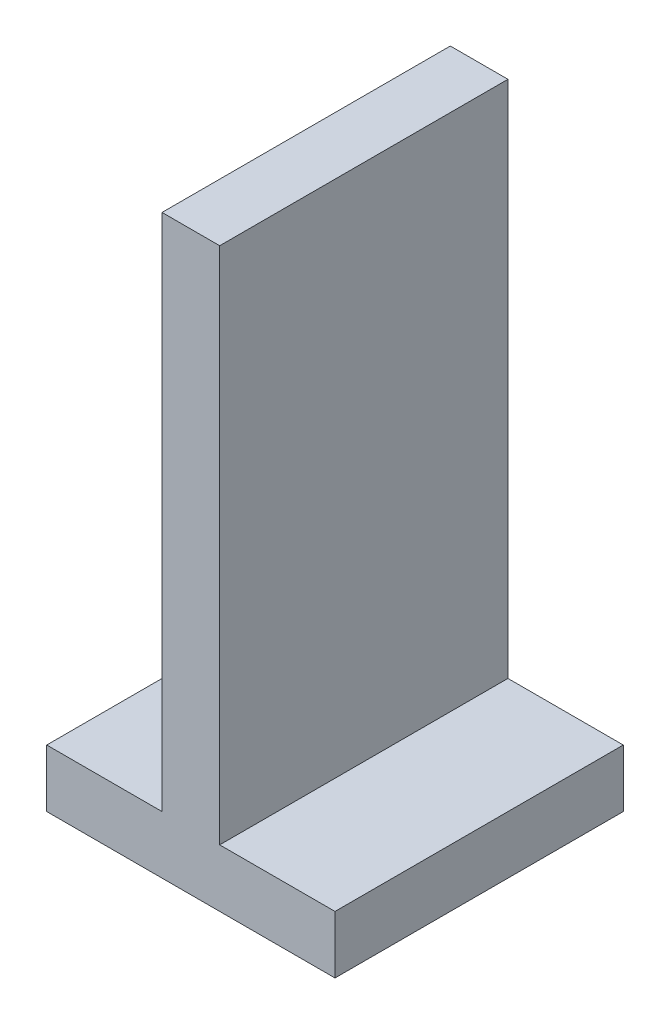
from build123d import *

# Parameters (mm, degrees)
BOSS_EXTRU_1_DEPTH = 500
BOSS_EXTRU_3_DEPTH = 600


with BuildPart() as part:
    # Esquisse1 → Boss.-Extru.1 (new body)
    with BuildSketch(Plane.XY):
        Polygon((0, 0), (500, 0), (500, 100), (300, 100), (300, 1000), (200, 1000), (200, 100), (0, 100), align=None)
    extrude(amount=BOSS_EXTRU_1_DEPTH)

    # Esquisse4 → Boss.-Extru.3 (add)
    with BuildSketch(Plane(origin=(0, 100, 0), x_dir=(1, 0, 0), z_dir=(0, 1, 0))):
        Polygon((200, -80), (200, -130), (190, -130), (190, -100), (185, -100), (185, -130), (175, -130), (175, -80), align=None)
        Polygon((175, -370), (175, -420), (200, -420), (200, -370), (190, -370), (190, -400), (185, -400), (185, -370), align=None)
    extrude(amount=BOSS_EXTRU_3_DEPTH)


solid = part.part
